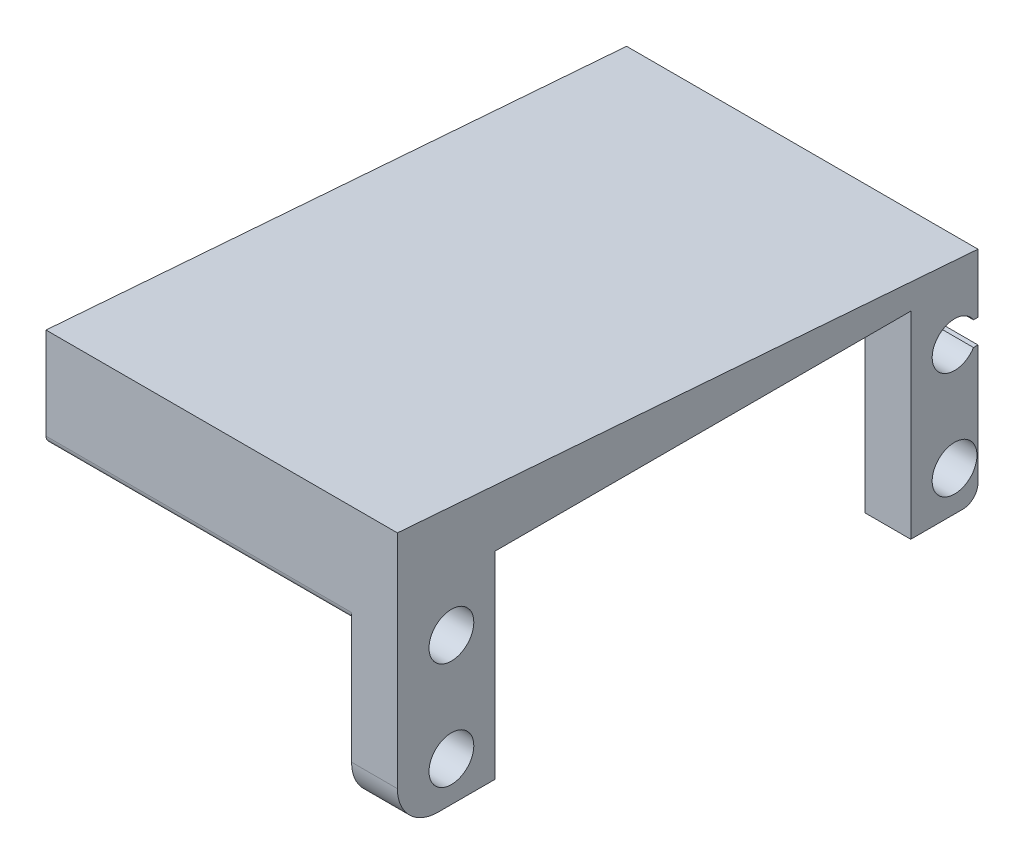
from build123d import *

# Parameters (mm, degrees)
SKETCH1_R           = 2.2
BOSS_EXTRUDE1_DEPTH = 4.5
BOSS_EXTRUDE2_DEPTH = 30


with BuildPart() as part:
    # Sketch1 → Boss-Extrude1 (new body)
    with BuildSketch(Plane(origin=(-110.040337845, 0, 0), x_dir=(0, 0, -1), z_dir=(1, 0, 0))):
        with BuildLine():
            Line((172.391431391, 38.831766631), (172.391431391, 58.231766631))
            Line((172.391431391, 58.231766631), (213.191431391, 58.231766631))
            Line((213.191431391, 58.231766631), (213.191431391, 38.831766631))
            Line((213.191431391, 38.831766631), (218.291431391, 38.831766631))
            ThreePointArc((218.291431391, 38.831766631), (219.352091563, 39.27110646), (219.791431391, 40.331766631))
            Line((219.791431391, 40.331766631), (219.791431391, 52.056766631))
            Line((219.791431391, 52.056766631), (219.351370906, 52.056766631))
            ThreePointArc((219.351370906, 52.056766631), (215.291431391, 53.231766631), (219.351370906, 54.406766631))
            Line((219.351370906, 54.406766631), (219.791431391, 54.406766631))
            Line((219.791431391, 54.406766631), (219.791431391, 60.200456158))
            Line((219.791431391, 60.200456158), (162.791431391, 64.577419509))
            Line((162.791431391, 64.577419509), (162.791431391, 42.831766631))
            ThreePointArc((162.791431391, 42.831766631), (163.963004266, 40.003339507), (166.791431391, 38.831766631))
            Line((166.791431391, 38.831766631), (172.391431391, 38.831766631))
        make_face()
        with Locations((168.091431391, 42.731766631)):
            Circle(SKETCH1_R, mode=Mode.SUBTRACT)
        with Locations((168.091431391, 53.231766631)):
            Circle(SKETCH1_R, mode=Mode.SUBTRACT)
        with Locations((217.491431391, 42.731766631)):
            Circle(SKETCH1_R, mode=Mode.SUBTRACT)
    extrude(amount=BOSS_EXTRUDE1_DEPTH)

    # Sketch1_3 → Boss-Extrude2 (add)
    with BuildSketch(Plane(origin=(-110.040337845, 0, 0), x_dir=(0, 0, -1), z_dir=(1, 0, 0))):
        with BuildLine():
            Line((162.791431391, 64.577419509), (162.791431391, 55.557459873))
            ThreePointArc((162.791431391, 55.557459873), (163.011101309, 55.027129783), (163.541431403, 54.807459873))
            Line((163.541431403, 54.807459873), (165.491431391, 54.807459873))
            Line((165.491431391, 54.807459873), (165.491431391, 57.431766631))
            Line((165.491431391, 57.431766631), (172.391431391, 57.431766631))
            Line((172.391431391, 57.431766631), (172.391431391, 58.231766631))
            Line((172.391431391, 58.231766631), (213.191431391, 58.231766631))
            Line((213.191431391, 58.231766631), (213.191431391, 57.431766631))
            Line((213.191431391, 57.431766631), (219.791431391, 57.431766631))
            Line((219.791431391, 57.431766631), (219.791431391, 60.200456158))
            Line((219.791431391, 60.200456158), (162.791431391, 64.577419509))
        make_face()
    extrude(amount=-BOSS_EXTRUDE2_DEPTH)


solid = part.part
